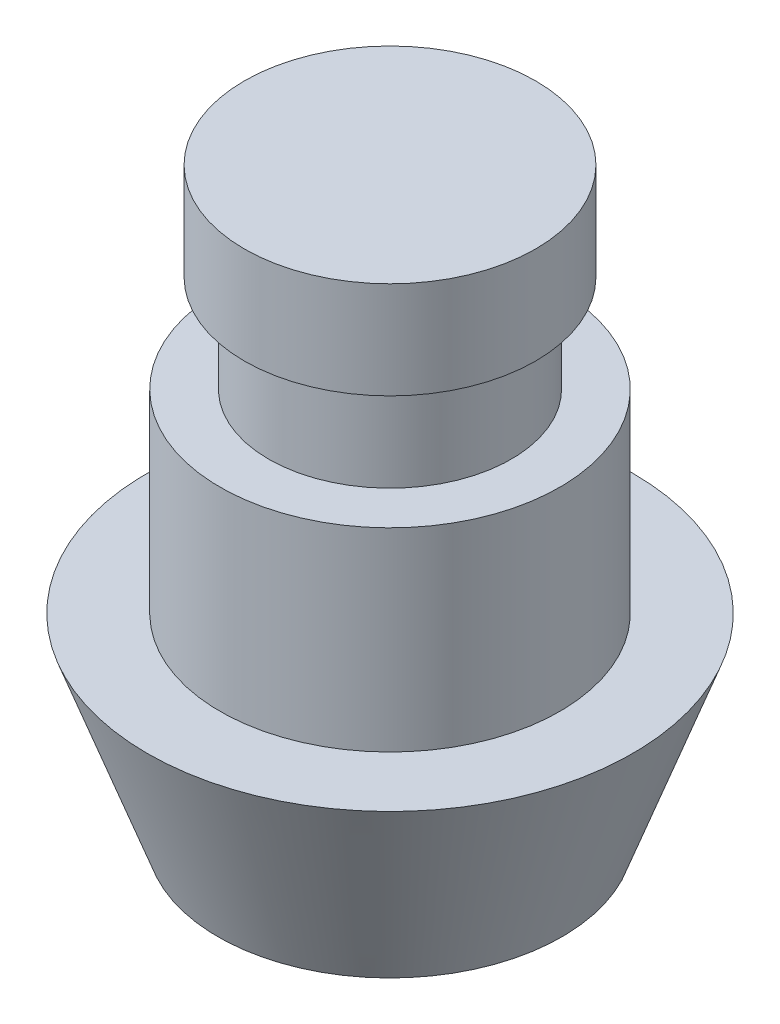
from build123d import *

# Parameters (mm, degrees)
SKETCH1_R           = 3
BOSS_EXTRUDE1_DEPTH = 2
SKETCH2_R           = 2.5
BOSS_EXTRUDE2_DEPTH = 2
SKETCH3_R           = 3.5
BOSS_EXTRUDE3_DEPTH = 4
SKETCH4_R           = 5
BOSS_EXTRUDE4_DEPTH = 4
BOSS_EXTRUDE4_TAPER = 20


with BuildPart() as part:
    # Sketch1 → Boss-Extrude1 (new body)
    with BuildSketch(Plane(origin=(0, 0, 0), x_dir=(1, 0, 0), z_dir=(0, 1, 0))):
        Circle(SKETCH1_R)
    extrude(amount=BOSS_EXTRUDE1_DEPTH)

    # Sketch2 → Boss-Extrude2 (add)
    with BuildSketch(Plane.XZ):
        Circle(SKETCH2_R)
    extrude(amount=BOSS_EXTRUDE2_DEPTH)

    # Sketch3 → Boss-Extrude3 (add)
    with BuildSketch(Plane.XZ.offset(2)):
        Circle(SKETCH3_R)
    extrude(amount=BOSS_EXTRUDE3_DEPTH)

    # Sketch4 → Boss-Extrude4 (add)
    with BuildSketch(Plane.XZ.offset(6)):
        Circle(SKETCH4_R)
    extrude(amount=BOSS_EXTRUDE4_DEPTH, taper=BOSS_EXTRUDE4_TAPER)


solid = part.part
